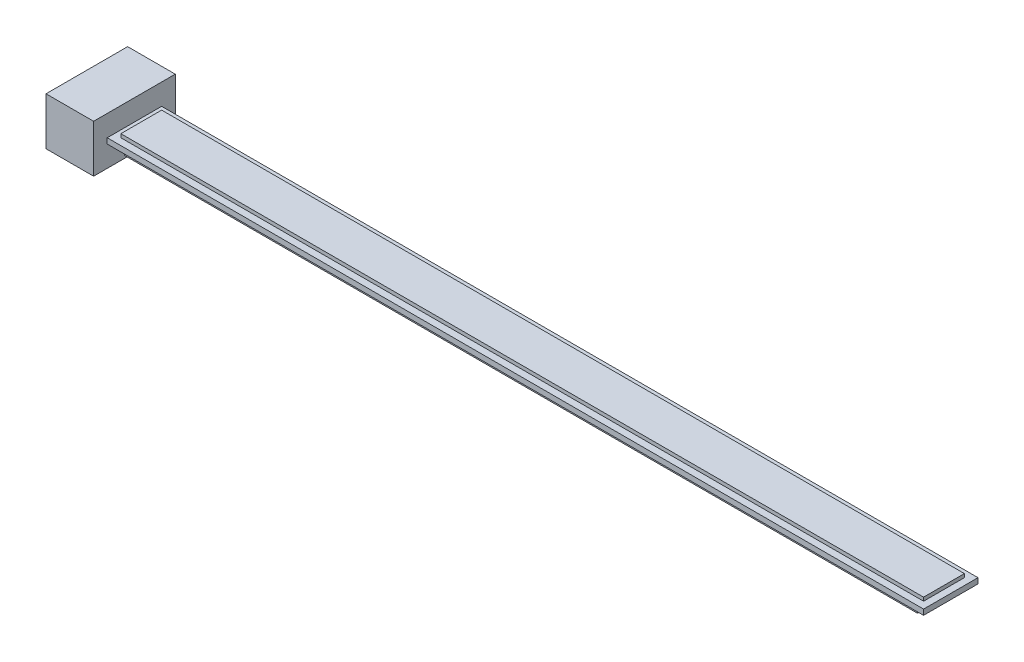
from build123d import *

# Parameters (mm, degrees)
SKETCH1_W           = 35
SKETCH1_H           = 35
BOSS_EXTRUDE1_DEPTH = 60
SKETCH2_W           = 40
SKETCH2_H           = 4
BOSS_EXTRUDE2_DEPTH = 600
SKETCH3_W           = 590
SKETCH3_H           = 30
BOSS_EXTRUDE3_DEPTH = 2.6
SKETCH4_W           = 582.794141244
SKETCH4_H           = 9.091842743
BOSS_EXTRUDE6_DEPTH = 5


with BuildPart() as part:
    # Sketch1 → Boss-Extrude1 (new body)
    with BuildSketch(Plane.XY):
        Rectangle(SKETCH1_W, SKETCH1_H)
    extrude(amount=BOSS_EXTRUDE1_DEPTH)

    # Sketch2 → Boss-Extrude2 (add)
    with BuildSketch(Plane(origin=(17.5, 0, 0), x_dir=(0, 0, -1), z_dir=(1, 0, 0))):
        with Locations((-30, 0)):
            Rectangle(SKETCH2_W, SKETCH2_H)
    extrude(amount=BOSS_EXTRUDE2_DEPTH)

    # Sketch3 → Boss-Extrude3 (add)
    with BuildSketch(Plane(origin=(0, 2, 0), x_dir=(1, 0, 0), z_dir=(0, 1, 0))):
        with Locations((317.5, -30)):
            Rectangle(SKETCH3_W, SKETCH3_H)
    extrude(amount=BOSS_EXTRUDE3_DEPTH)

    # Sketch4 → Boss-Extrude6 (add)
    with BuildSketch(Plane.XZ.offset(2)):
        with Locations((317.5, 41.36480343)):
            Rectangle(SKETCH4_W, SKETCH4_H)
    boss_extrude6 = extrude(amount=BOSS_EXTRUDE6_DEPTH)

    # Mirror1: Boss-Extrude6 across plane
    add(boss_extrude6.mirror(Plane.XY.offset(30)))


solid = part.part
